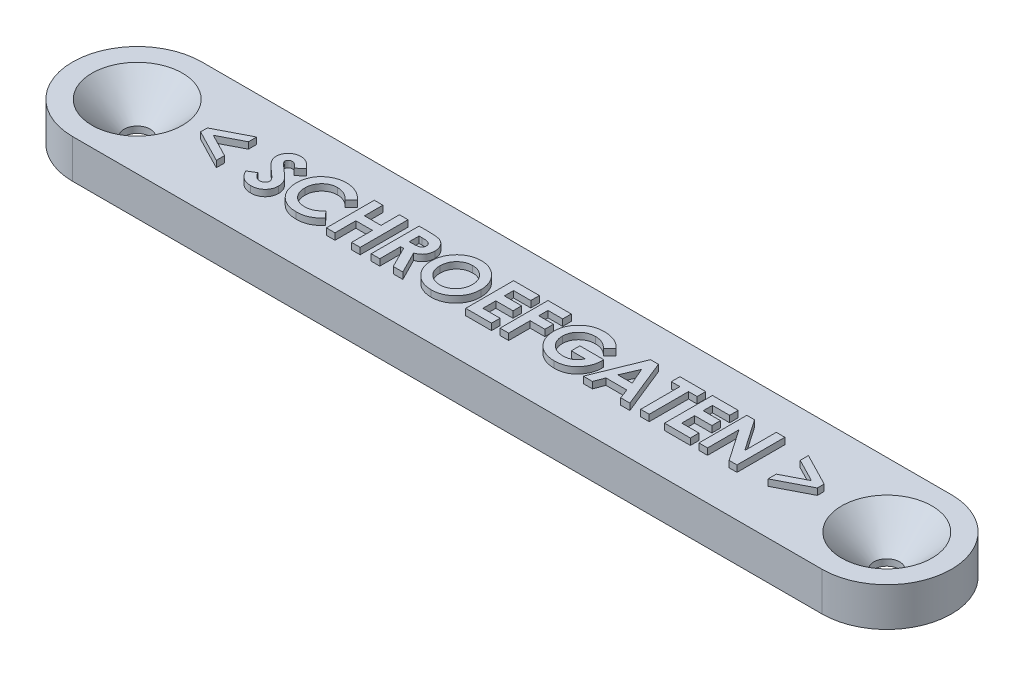
from build123d import *

# Parameters (mm, degrees)
SKETCH1_R           = 1
BOSS_EXTRUDE1_DEPTH = 3
CHAMFER1_SIZE       = 2.5
BOSS_EXTRUDE2_DEPTH = 0.5


with BuildPart() as part:
    # Sketch1 → Boss-Extrude1 (new body)
    with BuildSketch(Plane(origin=(0, 0, 0), x_dir=(1, 0, 0), z_dir=(0, 1, 0))):
        with BuildLine():
            Line((0, 5), (58, 5))
            ThreePointArc((58, 5), (63, 0), (58, -5))
            Line((58, -5), (0, -5))
            ThreePointArc((0, -5), (-5, 0), (0, 5))
        make_face()
        Circle(SKETCH1_R, mode=Mode.SUBTRACT)
        with Locations((58, 0)):
            Circle(SKETCH1_R, mode=Mode.SUBTRACT)
    extrude(amount=BOSS_EXTRUDE1_DEPTH)

    # Chamfer1
    chamfer1_edges = [part.edges().sort_by_distance(p)[0] for p in [
        (-1, 3, 0),
        (57, 3, 0),
    ]]
    chamfer(chamfer1_edges, length=CHAMFER1_SIZE)

    # Sketch2 → Boss-Extrude2 (add)
    with BuildSketch(Plane(origin=(0, 3, 0), x_dir=(1, 0, 0), z_dir=(0, 1, 0))):
        Polygon((7.65355235, -0.897702991), (7.65355235, -1.532130576), (5.13661859, -0.232852564), (5.13661859, 0.290271935), (7.65355235, 1.589549947), (7.65355235, 0.954380342), (5.859346621, 0.028338675), align=None)
        with BuildLine():
            Line((11.690144231, 1.409238949), (11.192990451, 0.954380342))
            add(Edge.make_bspline(
                [(11.192990451, 0.954380342), (11.171694515, 0.984420474), (11.130809288, 1.042093338), (11.064538598, 1.119318662), (10.998567155, 1.185197611), (10.932283772, 1.239454972), (10.86510094, 1.281761092), (10.797135277, 1.311714292), (10.728772101, 1.330755826), (10.682842599, 1.333126955), (10.660219685, 1.334294872)],
                knots=[0, 0, 0, 0, 0.000110419, 0.000211989, 0.00030486, 0.000389805, 0.000468459, 0.000542218, 0.000612051, 0.000679835, 0.000679835, 0.000679835, 0.000679835], degree=3))
            add(Edge.make_bspline(
                [(10.660219685, 1.334294872), (10.63911768, 1.333554826), (10.598375252, 1.332125992), (10.540293898, 1.317923488), (10.488728445, 1.293412051), (10.443729218, 1.261361286), (10.408083192, 1.222747545), (10.379622604, 1.182251658), (10.363596901, 1.137553358), (10.361487604, 1.106852763), (10.360443376, 1.091654147)],
                knots=[0, 0, 0, 0, 6.3229e-05, 0.000122078, 0.000177843, 0.000233653, 0.00028667, 0.000334827, 0.000381296, 0.000426857, 0.000426857, 0.000426857, 0.000426857], degree=3))
            add(Edge.make_bspline(
                [(10.360443376, 1.091654147), (10.361097741, 1.07623636), (10.36241554, 1.04518708), (10.375143685, 0.999680493), (10.394328634, 0.95521526), (10.412660636, 0.928147157), (10.422031083, 0.914311231)],
                knots=[0, 0, 0, 0, 4.6155e-05, 9.2949e-05, 0.000140791, 0.000190815, 0.000190815, 0.000190815, 0.000190815], degree=3))
            add(Edge.make_bspline(
                [(10.422031083, 0.914311231), (10.430549833, 0.903556711), (10.450158871, 0.878801225), (10.487549289, 0.839592394), (10.534503802, 0.791558144), (10.592829317, 0.736350233), (10.660104584, 0.671983167), (10.739447896, 0.600987241), (10.828575407, 0.521163793), (10.891925177, 0.465577634), (10.925121027, 0.436449987)],
                knots=[0, 0, 0, 0, 4.114e-05, 9.47e-05, 0.000162386, 0.000242679, 0.000335586, 0.000441703, 0.00056205, 0.000694537, 0.000694537, 0.000694537, 0.000694537], degree=3))
            add(Edge.make_bspline(
                [(10.925121027, 0.436449987), (10.956280107, 0.409483375), (11.015413568, 0.358306347), (11.099548739, 0.285668774), (11.173489542, 0.22031852), (11.238313126, 0.163236354), (11.293036827, 0.113823352), (11.337890706, 0.071843321), (11.373422575, 0.038113536), (11.393620362, 0.017740725), (11.402240251, 0.00904614)],
                knots=[0, 0, 0, 0, 0.000123624, 0.000234612, 0.000333454, 0.000419663, 0.000493735, 0.000554635, 0.000603967, 0.000640695, 0.000640695, 0.000640695, 0.000640695], degree=3))
            add(Edge.make_bspline(
                [(11.402240251, 0.00904614), (11.434942311, -0.026344492), (11.497807156, -0.094377718), (11.579509292, -0.199807821), (11.646752793, -0.302729099), (11.69877364, -0.405078183), (11.738061876, -0.508331766), (11.765760603, -0.615022138), (11.782349555, -0.726264145), (11.784191316, -0.802173235), (11.785122863, -0.840567408)],
                knots=[0, 0, 0, 0, 0.000144504, 0.000277787, 0.000399634, 0.000512794, 0.000621527, 0.000730412, 0.000842906, 0.000958037, 0.000958037, 0.000958037, 0.000958037], degree=3))
            add(Edge.make_bspline(
                [(11.785122863, -0.840567408), (11.784459812, -0.877977821), (11.783158881, -0.951378443), (11.767224966, -1.058789319), (11.744504138, -1.16158619), (11.709373753, -1.25865048), (11.666557047, -1.351575469), (11.612880123, -1.438913682), (11.549843936, -1.521549016), (11.477594786, -1.598004265), (11.397678648, -1.667382104), (11.311960994, -1.729143895), (11.219603635, -1.780136121), (11.121395657, -1.822124581), (11.017389629, -1.854464655), (10.907709453, -1.878366983), (10.792187366, -1.892712784), (10.713191699, -1.894212468), (10.672834034, -1.894978632)],
                knots=[0, 0, 0, 0, 0.000112134, 0.00022001, 0.000325126, 0.000427449, 0.000529028, 0.000631598, 0.000734298, 0.000840332, 0.000946573, 0.001051377, 0.001156673, 0.001262387, 0.001371279, 0.001482911, 0.001598785, 0.001719816, 0.001719816, 0.001719816, 0.001719816], degree=3))
            add(Edge.make_bspline(
                [(10.672834034, -1.894978632), (10.641153612, -1.894416601), (10.578408206, -1.893303455), (10.485930963, -1.884215551), (10.396633732, -1.869548639), (10.310617097, -1.848526573), (10.227493538, -1.821888765), (10.147259641, -1.789351703), (10.070469288, -1.750411074), (9.996541446, -1.705867653), (9.925835496, -1.654146874), (9.857457389, -1.596306151), (9.792086321, -1.531455868), (9.729408329, -1.459749394), (9.669824443, -1.380983672), (9.611384269, -1.296255662), (9.556685065, -1.203992926), (9.522894933, -1.139269871), (9.505635684, -1.106210771)],
                knots=[0, 0, 0, 0, 9.5025e-05, 0.000188204, 0.000278475, 0.0003663, 0.000453594, 0.000540128, 0.000625743, 0.000711642, 0.000798765, 0.000888264, 0.000980086, 0.001074739, 0.001173729, 0.001276224, 0.001383374, 0.001495244, 0.001495244, 0.001495244, 0.001495244], degree=3))
            Line((9.505635684, -1.106210771), (10.09034789, -0.755235043))
            add(Edge.make_bspline(
                [(10.09034789, -0.755235043), (10.111936631, -0.792761441), (10.153324093, -0.864702753), (10.223459017, -0.961365023), (10.295308666, -1.044140258), (10.370534139, -1.111565398), (10.448220724, -1.164542005), (10.528743664, -1.202402764), (10.612159533, -1.225838531), (10.668978633, -1.228700579), (10.697320713, -1.230128205)],
                knots=[0, 0, 0, 0, 0.000129801, 0.000248839, 0.000357663, 0.000458045, 0.000551067, 0.000638704, 0.000724023, 0.000808938, 0.000808938, 0.000808938, 0.000808938], degree=3))
            add(Edge.make_bspline(
                [(10.697320713, -1.230128205), (10.726148666, -1.228962329), (10.782079094, -1.226700358), (10.861912623, -1.205807221), (10.935107025, -1.173003463), (10.998375725, -1.126197023), (11.051947672, -1.072175277), (11.091486843, -1.012073615), (11.116325617, -0.947045068), (11.118951678, -0.901871961), (11.120272436, -0.879152477)],
                knots=[0, 0, 0, 0, 8.6333e-05, 0.000167499, 0.000245858, 0.000325563, 0.000402174, 0.000472974, 0.000540109, 0.00060804, 0.00060804, 0.00060804, 0.00060804], degree=3))
            add(Edge.make_bspline(
                [(11.120272436, -0.879152477), (11.11905277, -0.858015694), (11.116575135, -0.815078344), (11.098325642, -0.751237407), (11.069796117, -0.687425505), (11.036043678, -0.635085256), (11.001696344, -0.591262184), (10.968852546, -0.553291475), (10.928857489, -0.511340489), (10.881812581, -0.465356454), (10.82833941, -0.414934562), (10.768392931, -0.360079751), (10.701286693, -0.301275225), (10.653855871, -0.261218163), (10.629054821, -0.24027277)],
                knots=[0, 0, 0, 0, 6.335e-05, 0.00012869, 0.000197778, 0.000272501, 0.000314803, 0.000364784, 0.000423045, 0.000488633, 0.00056212, 0.000643529, 0.000732389, 0.000829775, 0.000829775, 0.000829775, 0.000829775], degree=3))
            add(Edge.make_bspline(
                [(10.629054821, -0.24027277), (10.581907038, -0.200381224), (10.491416172, -0.123817274), (10.363541097, -0.01073473), (10.248314204, 0.09495127), (10.146730718, 0.194547234), (10.057496307, 0.286213857), (9.981215304, 0.370695689), (9.918725693, 0.448644393), (9.852968852, 0.540969417), (9.790486705, 0.653473802), (9.736484399, 0.788829619), (9.701449983, 0.924168261), (9.697524864, 1.015027172), (9.695592949, 1.059747262)],
                knots=[0, 0, 0, 0, 0.000185273, 0.000355596, 0.00051208, 0.000654279, 0.00078232, 0.000895827, 0.000995603, 0.001081863, 0.001235664, 0.001380205, 0.001518422, 0.00165239, 0.00165239, 0.00165239, 0.00165239], degree=3))
            add(Edge.make_bspline(
                [(9.695592949, 1.059747262), (9.69639643, 1.09146035), (9.697979373, 1.15393854), (9.712099474, 1.245803614), (9.733202502, 1.334445692), (9.763850158, 1.419541367), (9.803627114, 1.500984054), (9.851934682, 1.579172447), (9.909522988, 1.65338692), (9.97442112, 1.723578272), (10.045922247, 1.787725181), (10.122330286, 1.844341255), (10.203212764, 1.892160015), (10.28807488, 1.931829148), (10.377442492, 1.96219335), (10.47065723, 1.98371701), (10.567852796, 1.996518596), (10.633963122, 1.998258823), (10.66763989, 1.999145299)],
                knots=[0, 0, 0, 0, 9.5083e-05, 0.000187324, 0.000278208, 0.000368103, 0.000458038, 0.00054967, 0.000643321, 0.000739409, 0.000836094, 0.000931076, 0.001024228, 0.001117513, 0.00121161, 0.001306826, 0.00140411, 0.001505122, 0.001505122, 0.001505122, 0.001505122], degree=3))
            add(Edge.make_bspline(
                [(10.66763989, 1.999145299), (10.711283316, 1.99754873), (10.798225662, 1.994368193), (10.926772427, 1.969497439), (11.052331534, 1.930385559), (11.153509414, 1.883201378), (11.234014766, 1.83749404), (11.295714597, 1.79541248), (11.358497497, 1.747205792), (11.422869769, 1.692722064), (11.487635279, 1.630934749), (11.554635619, 1.563314745), (11.622957826, 1.489277656), (11.667356429, 1.436385902), (11.690144231, 1.409238949)],
                knots=[0, 0, 0, 0, 0.00013085, 0.000260668, 0.000391384, 0.000524522, 0.000594654, 0.000668949, 0.000748348, 0.000832052, 0.000921812, 0.001016782, 0.001117609, 0.001223928, 0.001223928, 0.001223928, 0.001223928], degree=3))
        make_face()
        with BuildLine():
            Line((15.774225427, 1.261576856), (15.286717915, 0.795587941))
            add(Edge.make_bspline(
                [(15.286717915, 0.795587941), (15.245363557, 0.838348417), (15.164585538, 0.921873024), (15.034421751, 1.032452242), (14.899056152, 1.124605059), (14.761122008, 1.202215574), (14.618138284, 1.26093346), (14.471758262, 1.303722173), (14.321047261, 1.329808834), (14.219051853, 1.33279361), (14.167750901, 1.334294872)],
                knots=[0, 0, 0, 0, 0.000178394, 0.000348459, 0.000511259, 0.000669024, 0.000822394, 0.000973856, 0.001125852, 0.001279667, 0.001279667, 0.001279667, 0.001279667], degree=3))
            add(Edge.make_bspline(
                [(14.167750901, 1.334294872), (14.124908373, 1.333108822), (14.040363363, 1.330768284), (13.916229134, 1.313609833), (13.797488329, 1.284431139), (13.683734478, 1.244217494), (13.575302308, 1.192183172), (13.471964478, 1.128368446), (13.373975761, 1.053349654), (13.282630533, 0.967514946), (13.199071128, 0.873734077), (13.125241073, 0.773670114), (13.06339656, 0.667552297), (13.012641773, 0.55645531), (12.973105757, 0.439864941), (12.944872073, 0.317859683), (12.928542466, 0.190294237), (12.926105162, 0.103576198), (12.924866453, 0.059503539)],
                knots=[0, 0, 0, 0, 0.000128507, 0.000253594, 0.000375072, 0.000494766, 0.000614909, 0.000735173, 0.000858503, 0.000984498, 0.001110637, 0.001234859, 0.001356905, 0.001478435, 0.001600689, 0.001725604, 0.001853535, 0.001985748, 0.001985748, 0.001985748, 0.001985748], degree=3))
            add(Edge.make_bspline(
                [(12.924866453, 0.059503539), (12.925223435, 0.028570263), (12.925927054, -0.032399858), (12.933629404, -0.12259159), (12.946032004, -0.210098892), (12.963981639, -0.294789214), (12.986427835, -0.37673595), (13.012762333, -0.456646049), (13.045798574, -0.533415335), (13.082469299, -0.607935432), (13.12511693, -0.678172967), (13.171098944, -0.745150286), (13.220958931, -0.808539072), (13.275019837, -0.868080191), (13.334042501, -0.922843148), (13.396501407, -0.97447473), (13.46345015, -1.021682424), (13.533498034, -1.065650959), (13.607250185, -1.103846799), (13.682705536, -1.138444852), (13.761008143, -1.166543614), (13.841204623, -1.18919378), (13.923008383, -1.208454364), (14.007219541, -1.220313697), (14.093108089, -1.229294631), (14.151154332, -1.229849151), (14.180365251, -1.230128205)],
                knots=[0, 0, 0, 0, 9.2779e-05, 0.00018287, 0.000271332, 0.000357777, 0.00044238, 0.00052615, 0.000609942, 0.000692903, 0.00077511, 0.000856204, 0.000936514, 0.001016875, 0.001097195, 0.001177857, 0.001259803, 0.001342783, 0.00142576, 0.001508787, 0.001591644, 0.001675018, 0.001758722, 0.001843514, 0.001929975, 0.002017561, 0.002017561, 0.002017561, 0.002017561], degree=3))
            add(Edge.make_bspline(
                [(14.180365251, -1.230128205), (14.229911991, -1.22869505), (14.32725845, -1.225879274), (14.470128376, -1.203860303), (14.606269182, -1.167640342), (14.715045035, -1.124866672), (14.800268042, -1.082627118), (14.865147058, -1.04355761), (14.932237017, -0.999854076), (15.000423612, -0.949867097), (15.070473807, -0.894196538), (15.141151056, -0.831623107), (15.214264707, -0.76420726), (15.262160735, -0.716091246), (15.286717915, -0.691421274)],
                knots=[0, 0, 0, 0, 0.00014859, 0.00029194, 0.000432513, 0.000570443, 0.000641789, 0.000717635, 0.000797488, 0.000881938, 0.000971169, 0.001065822, 0.001165056, 0.00126947, 0.00126947, 0.00126947, 0.00126947], degree=3))
            Line((15.286717915, -0.691421274), (15.759385016, -1.187833033))
            add(Edge.make_bspline(
                [(15.759385016, -1.187833033), (15.726159063, -1.219911647), (15.661309108, -1.282522243), (15.563484752, -1.371423446), (15.465783511, -1.451311059), (15.370565645, -1.525084654), (15.276271385, -1.590595025), (15.182910731, -1.647907599), (15.091540567, -1.698471894), (15.000263561, -1.741435168), (14.908511742, -1.77791545), (14.814109901, -1.809322578), (14.716769446, -1.835891879), (14.615895863, -1.857329815), (14.512430041, -1.874520145), (14.405403676, -1.886123519), (14.295495369, -1.893924081), (14.220942862, -1.894625026), (14.183333333, -1.894978632)],
                knots=[0, 0, 0, 0, 0.000138553, 0.000270426, 0.000396406, 0.000517066, 0.000631715, 0.000740653, 0.000845591, 0.000944838, 0.001043083, 0.001141635, 0.001243159, 0.001345617, 0.001450892, 0.001557663, 0.001668473, 0.001781282, 0.001781282, 0.001781282, 0.001781282], degree=3))
            add(Edge.make_bspline(
                [(14.183333333, -1.894978632), (14.114249287, -1.893217542), (13.979071012, -1.889771579), (13.780970775, -1.86423932), (13.592780867, -1.821434938), (13.414043458, -1.760897735), (13.244815382, -1.683564296), (13.085139933, -1.588757131), (12.935274472, -1.476728128), (12.796429617, -1.348790375), (12.670837837, -1.207493868), (12.559829248, -1.055780182), (12.46800294, -0.8929037), (12.391757577, -0.721270629), (12.332134706, -0.540097741), (12.290170313, -0.34918906), (12.264291177, -0.148728922), (12.261459963, -0.011810027), (12.260016026, 0.058019498)],
                knots=[0, 0, 0, 0, 0.000207215, 0.000405462, 0.000598064, 0.000785315, 0.00097059, 0.001155239, 0.001341339, 0.001530914, 0.001720647, 0.00190766, 0.002093758, 0.002280452, 0.002470283, 0.002664892, 0.002866084, 0.003075493, 0.003075493, 0.003075493, 0.003075493], degree=3))
            add(Edge.make_bspline(
                [(12.260016026, 0.058019498), (12.260626164, 0.103561718), (12.261835308, 0.193815268), (12.274543529, 0.326766059), (12.292259527, 0.456369299), (12.320364347, 0.581279276), (12.354241936, 0.70317876), (12.396373169, 0.820742844), (12.446690757, 0.934309419), (12.503572844, 1.044068604), (12.567922981, 1.149301357), (12.639809148, 1.249103564), (12.717380715, 1.344245679), (12.8025016, 1.433465465), (12.893934886, 1.517546289), (12.992093383, 1.596032502), (13.096386717, 1.670049684), (13.207097172, 1.737689112), (13.322073937, 1.798872569), (13.439866854, 1.852838992), (13.560186518, 1.897942493), (13.682524209, 1.935354184), (13.8073968, 1.963279366), (13.933912983, 1.984417828), (14.063149258, 1.996234363), (14.149920221, 1.998168806), (14.193721621, 1.999145299)],
                knots=[0, 0, 0, 0, 0.000136582, 0.000270673, 0.000400375, 0.000528747, 0.000654421, 0.000779754, 0.000903012, 0.001026805, 0.001150375, 0.00127269, 0.001395536, 0.001518353, 0.001642291, 0.001767909, 0.001895142, 0.002025712, 0.002156831, 0.00228567, 0.002414116, 0.002542048, 0.002669133, 0.002797708, 0.002926625, 0.003058038, 0.003058038, 0.003058038, 0.003058038], degree=3))
            add(Edge.make_bspline(
                [(14.193721621, 1.999145299), (14.231088707, 1.998585549), (14.305434364, 1.997471868), (14.416147523, 1.988188125), (14.52597525, 1.973608101), (14.634524328, 1.951609949), (14.742571211, 1.925495363), (14.848696042, 1.891301915), (14.954572997, 1.853186874), (15.058541555, 1.807628124), (15.160746838, 1.757896634), (15.258794529, 1.701474452), (15.354330837, 1.641833736), (15.445238737, 1.575444689), (15.533221129, 1.504715363), (15.617817946, 1.429315767), (15.6982868, 1.347988768), (15.748784584, 1.290526443), (15.774225427, 1.261576856)],
                knots=[0, 0, 0, 0, 0.000112084, 0.000223003, 0.000333085, 0.000444265, 0.000555124, 0.000666363, 0.000778573, 0.000892569, 0.001006724, 0.001119377, 0.001231775, 0.001344431, 0.001456839, 0.001570346, 0.001684205, 0.001799807, 0.001799807, 0.001799807, 0.001799807], degree=3))
        make_face()
        Polygon((16.439075855, 1.904166667), (17.103926282, 1.904166667), (17.103926282, 0.479487179), (18.386137821, 0.479487179), (18.386137821, 1.904166667), (19.050988248, 1.904166667), (19.050988248, -1.8), (18.386137821, -1.8), (18.386137821, -0.185363248), (17.103926282, -0.185363248), (17.103926282, -1.8), (16.439075855, -1.8), align=None)
        with BuildLine():
            Line((19.90579594, 1.904166667), (20.680465411, 1.904166667))
            add(Edge.make_bspline(
                [(20.680465411, 1.904166667), (20.731670828, 1.903984917), (20.830153267, 1.903635361), (20.972159565, 1.898120291), (21.102611879, 1.890445618), (21.221703355, 1.878733864), (21.329383045, 1.863205494), (21.425758867, 1.844900116), (21.510828005, 1.824037212), (21.585307901, 1.798040388), (21.652522323, 1.768716365), (21.715175509, 1.735022525), (21.774649682, 1.697334059), (21.830547321, 1.654659282), (21.883354188, 1.607765903), (21.933169909, 1.556606718), (21.979290539, 1.50074792), (22.0214305, 1.440542464), (22.059837681, 1.377207705), (22.093781575, 1.310656684), (22.121384805, 1.240843118), (22.145775218, 1.168775966), (22.163342843, 1.093425013), (22.175560868, 1.015523813), (22.184506429, 0.934798146), (22.185020756, 0.879956711), (22.18528312, 0.851981504)],
                knots=[0, 0, 0, 0, 0.000153605, 0.000295427, 0.000426277, 0.000545592, 0.000654308, 0.000752538, 0.000839823, 0.000916793, 0.000988895, 0.001059605, 0.001130003, 0.001199903, 0.001270336, 0.001341702, 0.001413907, 0.0014874, 0.001561973, 0.001635974, 0.001711208, 0.001786999, 0.00186403, 0.001942957, 0.00202351, 0.002107388, 0.002107388, 0.002107388, 0.002107388], degree=3))
            add(Edge.make_bspline(
                [(22.18528312, 0.851981504), (22.184601593, 0.822781813), (22.183265243, 0.765526543), (22.176066938, 0.681423219), (22.162910697, 0.600959043), (22.142983655, 0.524369601), (22.120080109, 0.450701651), (22.089624269, 0.38131441), (22.055251842, 0.315198744), (22.014428715, 0.253289882), (21.969627328, 0.194212705), (21.917524257, 0.140230679), (21.861494981, 0.088442475), (21.79838989, 0.042091929), (21.730990716, -0.001955014), (21.657958307, -0.041873274), (21.579769298, -0.078666305), (21.524798553, -0.099184641), (21.496688034, -0.10967715)],
                knots=[0, 0, 0, 0, 8.7609e-05, 0.000171785, 0.000253028, 0.000331854, 0.000409056, 0.000484176, 0.000558859, 0.000632334, 0.000706395, 0.00078093, 0.000857099, 0.000935011, 0.001015485, 0.001098512, 0.00118449, 0.001274471, 0.001274471, 0.001274471, 0.001274471], degree=3))
            Line((21.496688034, -0.10967715), (22.351495726, -1.8))
            Line((22.351495726, -1.8), (21.612443243, -1.8))
            Line((21.612443243, -1.8), (20.79622062, -0.185363248))
            Line((20.79622062, -0.185363248), (20.570646368, -0.185363248))
            Line((20.570646368, -0.185363248), (20.570646368, -1.8))
            Line((20.570646368, -1.8), (19.90579594, -1.8))
            Line((19.90579594, -1.8), (19.90579594, 1.904166667))
        make_face()
        with BuildLine():
            Line((20.570646368, 0.479487179), (20.829611545, 0.479487179))
            add(Edge.make_bspline(
                [(20.829611545, 0.479487179), (20.861272191, 0.479843763), (20.921895524, 0.480526544), (21.00907984, 0.483693564), (21.088263991, 0.491324517), (21.15978802, 0.500965941), (21.224011831, 0.512098358), (21.28036257, 0.528051787), (21.329708515, 0.54514629), (21.371464914, 0.566390323), (21.407140623, 0.590549396), (21.437944314, 0.617994704), (21.463423383, 0.649759153), (21.484393956, 0.684979522), (21.500706783, 0.723967328), (21.512613896, 0.766294572), (21.519268212, 0.812443416), (21.520033813, 0.844292402), (21.520432692, 0.860885751)],
                knots=[0, 0, 0, 0, 9.499e-05, 0.000181886, 0.000261628, 0.000333512, 0.000398421, 0.000456928, 0.000509039, 0.000554834, 0.000597025, 0.000638004, 0.000678101, 0.000718696, 0.000760592, 0.000804522, 0.000850275, 0.00090004, 0.00090004, 0.00090004, 0.00090004], degree=3))
            add(Edge.make_bspline(
                [(21.520432692, 0.860885751), (21.519678575, 0.880516893), (21.518197251, 0.919078635), (21.503497914, 0.974594022), (21.480099744, 1.025977311), (21.448027262, 1.072996339), (21.407636141, 1.114216465), (21.361284143, 1.150552334), (21.307970879, 1.179284021), (21.258606809, 1.198235136), (21.213697044, 1.209573783), (21.173167397, 1.218023243), (21.126233823, 1.224011617), (21.072860888, 1.230363355), (21.013184642, 1.234482135), (20.946879814, 1.237488023), (20.87413683, 1.23871788), (20.823428062, 1.239111043), (20.79696264, 1.239316239)],
                knots=[0, 0, 0, 0, 5.8788e-05, 0.000115479, 0.000170932, 0.000227531, 0.000285256, 0.000343437, 0.000403545, 0.000466249, 0.000501525, 0.000542417, 0.000590373, 0.00064339, 0.000703658, 0.000769765, 0.000842498, 0.000921898, 0.000921898, 0.000921898, 0.000921898], degree=3))
            Line((20.79696264, 1.239316239), (20.570646368, 1.239316239))
            Line((20.570646368, 1.239316239), (20.570646368, 0.479487179))
        make_face(mode=Mode.SUBTRACT)
        with BuildLine():
            add(Edge.make_bspline(
                [(24.638403112, 1.999145299), (24.702804589, 1.99747783), (24.829947691, 1.994185867), (25.016929314, 1.966744789), (25.197120681, 1.922033487), (25.370440308, 1.859881544), (25.536454225, 1.778605568), (25.695748018, 1.680509787), (25.847751104, 1.563742702), (25.990905877, 1.431028297), (26.123206705, 1.286707176), (26.237845451, 1.131319831), (26.335605167, 0.968892504), (26.416628681, 0.798989967), (26.478343169, 0.620435563), (26.521650777, 0.434139684), (26.54947377, 0.240155329), (26.552673842, 0.108078423), (26.554300214, 0.040953025)],
                knots=[0, 0, 0, 0, 0.000193131, 0.000381284, 0.000565569, 0.000749353, 0.00093254, 0.001119111, 0.00130967, 0.001506585, 0.001704094, 0.001896132, 0.002084852, 0.002272053, 0.002459786, 0.002650387, 0.002845153, 0.003046437, 0.003046437, 0.003046437, 0.003046437], degree=3))
            add(Edge.make_bspline(
                [(26.554300214, 0.040953025), (26.552568198, -0.025416025), (26.549155206, -0.156198368), (26.522786633, -0.348395081), (26.47874972, -0.532695343), (26.418081958, -0.709516322), (26.338527904, -0.878001559), (26.242674609, -1.039226808), (26.127992686, -1.191695859), (25.998665036, -1.335326893), (25.856286516, -1.465702876), (25.705485062, -1.580596486), (25.546956981, -1.677952995), (25.380934307, -1.75772781), (25.207061013, -1.819638106), (25.025766587, -1.863320318), (24.837062248, -1.88986688), (24.708734146, -1.893257579), (24.643597256, -1.894978632)],
                knots=[0, 0, 0, 0, 0.000199061, 0.000392256, 0.000580691, 0.000766778, 0.000952004, 0.001138688, 0.001328498, 0.001523412, 0.001717728, 0.001906798, 0.002091327, 0.002274859, 0.002458392, 0.002643942, 0.002833461, 0.003028815, 0.003028815, 0.003028815, 0.003028815], degree=3))
            add(Edge.make_bspline(
                [(24.643597256, -1.894978632), (24.575471878, -1.893434762), (24.441614824, -1.890401269), (24.245714425, -1.86155413), (24.058024916, -1.818100261), (23.880122997, -1.753247693), (23.710196888, -1.672176531), (23.549495086, -1.572332533), (23.398071598, -1.453880701), (23.256795014, -1.319854629), (23.128798087, -1.17320071), (23.015815692, -1.018273849), (22.920512536, -0.856257553), (22.842885131, -0.687075993), (22.781686803, -0.511780592), (22.738518336, -0.32930375), (22.713017693, -0.140083113), (22.709465601, -0.011560674), (22.707665598, 0.053567374)],
                knots=[0, 0, 0, 0, 0.00020425, 0.000401323, 0.000592818, 0.000781292, 0.000968143, 0.001156756, 0.001347635, 0.001543938, 0.001740086, 0.001930808, 0.002118391, 0.002302992, 0.002488378, 0.002674476, 0.00286463, 0.003059984, 0.003059984, 0.003059984, 0.003059984], degree=3))
            add(Edge.make_bspline(
                [(22.707665598, 0.053567374), (22.708230543, 0.097382116), (22.709353279, 0.184456803), (22.722877815, 0.313497045), (22.742349258, 0.440018595), (22.771146599, 0.563517009), (22.806128008, 0.684863511), (22.851451364, 0.802928579), (22.903041609, 0.918973471), (22.963319954, 1.031627552), (23.030343644, 1.139854311), (23.103472457, 1.243143223), (23.182890275, 1.340245374), (23.268341267, 1.431798879), (23.360119907, 1.517201951), (23.457018944, 1.597663589), (23.560917653, 1.671046445), (23.669542019, 1.739142676), (23.782279642, 1.800720917), (23.898671577, 1.853134474), (24.016319922, 1.89890634), (24.136796298, 1.935031521), (24.258809588, 1.964455103), (24.383663256, 1.983913423), (24.51022932, 1.997437584), (24.59557712, 1.99857471), (24.638403112, 1.999145299)],
                knots=[0, 0, 0, 0, 0.00013139, 0.000261116, 0.000388841, 0.000515202, 0.000641287, 0.000767389, 0.000894264, 0.001022066, 0.001150352, 0.001275944, 0.001401453, 0.001526399, 0.001651346, 0.001777325, 0.001903952, 0.00203263, 0.002161789, 0.002288969, 0.002415335, 0.002540211, 0.002666018, 0.002791544, 0.002919055, 0.003047478, 0.003047478, 0.003047478, 0.003047478], degree=3))
        make_face()
        with BuildLine():
            add(Edge.make_bspline(
                [(24.628014824, 1.334294872), (24.584672638, 1.333131904), (24.499132508, 1.33083667), (24.373660715, 1.313350093), (24.253203362, 1.285422042), (24.138428193, 1.244968602), (24.028837762, 1.193481639), (23.924237798, 1.131141056), (23.826076796, 1.055803965), (23.733045874, 0.971514878), (23.649007743, 0.877597464), (23.574757404, 0.776948983), (23.512621829, 0.669737516), (23.460582896, 0.556959032), (23.421409113, 0.437345367), (23.393506802, 0.311833467), (23.375873583, 0.18020707), (23.373650893, 0.090477526), (23.372516026, 0.044663128)],
                knots=[0, 0, 0, 0, 0.000129989, 0.000256547, 0.000379294, 0.000500387, 0.000620883, 0.00074203, 0.00086491, 0.000991491, 0.001118125, 0.001242346, 0.001366048, 0.001489237, 0.001614304, 0.001742837, 0.001874543, 0.002011945, 0.002011945, 0.002011945, 0.002011945], degree=3))
            add(Edge.make_bspline(
                [(23.372516026, 0.044663128), (23.374020687, -0.006109532), (23.376969574, -0.105615532), (23.397718302, -0.250772203), (23.43321731, -0.387858273), (23.484477188, -0.516203273), (23.548052885, -0.637232378), (23.62700381, -0.749462206), (23.720051332, -0.853564735), (23.79173439, -0.914344127), (23.828116653, -0.945192308)],
                knots=[0, 0, 0, 0, 0.000152295, 0.000298473, 0.000438856, 0.000576096, 0.000712192, 0.000848054, 0.000986766, 0.001129728, 0.001129728, 0.001129728, 0.001129728], degree=3))
            add(Edge.make_bspline(
                [(23.828116653, -0.945192308), (23.857920673, -0.967981759), (23.916857223, -1.01304721), (24.010932788, -1.070807831), (24.107812096, -1.120314446), (24.208226222, -1.160315205), (24.311963097, -1.191779129), (24.419008496, -1.213812798), (24.529210744, -1.227640831), (24.603734669, -1.229293543), (24.641371194, -1.230128205)],
                knots=[0, 0, 0, 0, 0.000112494, 0.000222453, 0.000330636, 0.000438525, 0.000546271, 0.000655417, 0.000766045, 0.00087892, 0.00087892, 0.00087892, 0.00087892], degree=3))
            add(Edge.make_bspline(
                [(24.641371194, -1.230128205), (24.68396811, -1.228955376), (24.767778881, -1.226647799), (24.890914949, -1.209376491), (25.008883042, -1.180147203), (25.122415516, -1.140048634), (25.231184994, -1.087915209), (25.33465989, -1.023641016), (25.433021624, -0.948015262), (25.525934027, -0.862619275), (25.610860355, -0.768331891), (25.684955749, -0.667146562), (25.749066925, -0.561292701), (25.800023707, -0.449272109), (25.840745158, -0.332142208), (25.86831165, -0.209384254), (25.88609383, -0.081504302), (25.888317146, 0.005522525), (25.889449786, 0.049857272)],
                knots=[0, 0, 0, 0, 0.000127766, 0.000251383, 0.000372141, 0.000491834, 0.000611977, 0.000733263, 0.000856592, 0.000983675, 0.001111357, 0.001236615, 0.001359417, 0.001481931, 0.001605127, 0.001730765, 0.001858793, 0.001991748, 0.001991748, 0.001991748, 0.001991748], degree=3))
            add(Edge.make_bspline(
                [(25.889449786, 0.049857272), (25.888277956, 0.093937081), (25.885971387, 0.180701464), (25.868669681, 0.308252638), (25.839625757, 0.430468652), (25.799406777, 0.547549097), (25.748049269, 0.659608757), (25.6845405, 0.766253564), (25.609103315, 0.867380417), (25.523473895, 0.962300176), (25.430271535, 1.049525354), (25.330209489, 1.125220953), (25.226087605, 1.190998022), (25.115516819, 1.242525121), (25.000759317, 1.283576652), (24.881114842, 1.313807589), (24.756130234, 1.330713826), (24.671100621, 1.33309055), (24.628014824, 1.334294872)],
                knots=[0, 0, 0, 0, 0.000132213, 0.000260241, 0.000385326, 0.000508522, 0.000631036, 0.000754475, 0.000880174, 0.001008904, 0.001137539, 0.001262498, 0.001384806, 0.001506289, 0.001627629, 0.001750006, 0.001875829, 0.002005077, 0.002005077, 0.002005077, 0.002005077], degree=3))
        make_face(mode=Mode.SUBTRACT)
        Polygon((27.219150641, 1.904166667), (29.213701923, 1.904166667), (29.213701923, 1.239316239), (27.884001068, 1.239316239), (27.884001068, 0.526976496), (29.213701923, 0.526976496), (29.213701923, -0.137873932), (27.884001068, -0.137873932), (27.884001068, -1.135149573), (29.213701923, -1.135149573), (29.213701923, -1.8), (27.219150641, -1.8), align=None)
        Polygon((29.87855235, 1.904166667), (31.683146368, 1.904166667), (31.683146368, 1.239316239), (30.543402778, 1.239316239), (30.543402778, 0.526976496), (31.683146368, 0.526976496), (31.683146368, -0.137873932), (30.543402778, -0.137873932), (30.543402778, -1.8), (29.87855235, -1.8), align=None)
        with BuildLine():
            Line((35.742740885, 1.315002337), (35.239650942, 0.83343099))
            add(Edge.make_bspline(
                [(35.239650942, 0.83343099), (35.199820433, 0.873309222), (35.121666399, 0.951556898), (34.993855253, 1.053401627), (34.861481696, 1.139989779), (34.724110032, 1.211188615), (34.581548903, 1.266416622), (34.434079642, 1.305922983), (34.281462336, 1.329354875), (34.178147232, 1.33263526), (34.125878072, 1.334294872)],
                knots=[0, 0, 0, 0, 0.000168979, 0.000331564, 0.000489215, 0.000642871, 0.000794862, 0.000946954, 0.001100064, 0.001256843, 0.001256843, 0.001256843, 0.001256843], degree=3))
            add(Edge.make_bspline(
                [(34.125878072, 1.334294872), (34.080562307, 1.333131989), (33.991580832, 1.330848567), (33.860831124, 1.313508419), (33.735891769, 1.28454248), (33.616172502, 1.244415008), (33.502404249, 1.192196485), (33.393927818, 1.128692841), (33.291410773, 1.05341827), (33.195660361, 0.967799714), (33.108479303, 0.874321538), (33.032365636, 0.774266835), (32.967533143, 0.669500541), (32.914162779, 0.559486654), (32.873553736, 0.444394025), (32.844564194, 0.324306206), (32.826163043, 0.199572187), (32.823990417, 0.114477347), (32.822889957, 0.071375868)],
                knots=[0, 0, 0, 0, 0.000135919, 0.00026689, 0.000394864, 0.000520167, 0.000645014, 0.000769731, 0.000896625, 0.001025907, 0.001154542, 0.001279502, 0.00140244, 0.001523573, 0.001645613, 0.001767812, 0.001893737, 0.002022985, 0.002022985, 0.002022985, 0.002022985], degree=3))
            add(Edge.make_bspline(
                [(32.822889957, 0.071375868), (32.823916413, 0.026782589), (32.825938671, -0.061072276), (32.845364749, -0.190003066), (32.875293966, -0.314043777), (32.91910236, -0.432274056), (32.973017226, -0.546313492), (33.041390159, -0.653953032), (33.12111984, -0.756836451), (33.212063805, -0.85317249), (33.310987353, -0.941971132), (33.418124773, -1.018571127), (33.53021629, -1.084660388), (33.649071065, -1.137000947), (33.77262613, -1.179024681), (33.90213469, -1.20865502), (34.037305122, -1.22683313), (34.12953069, -1.229018913), (34.17633547, -1.230128205)],
                knots=[0, 0, 0, 0, 0.000133696, 0.000263399, 0.000390275, 0.000515861, 0.000640981, 0.000768008, 0.000897581, 0.001030918, 0.001164945, 0.001295713, 0.001425397, 0.001554607, 0.001684602, 0.001816358, 0.001952575, 0.002092943, 0.002092943, 0.002092943, 0.002092943], degree=3))
            add(Edge.make_bspline(
                [(34.17633547, -1.230128205), (34.206780247, -1.229853507), (34.266550117, -1.229314214), (34.354222331, -1.220559969), (34.438191254, -1.208044757), (34.518782075, -1.191476104), (34.595181042, -1.168028486), (34.668445951, -1.140609384), (34.738147535, -1.108249377), (34.803907879, -1.069831983), (34.866705688, -1.026770781), (34.925953162, -0.977499609), (34.98268957, -0.923129351), (35.036251957, -0.862995796), (35.085733762, -0.79656128), (35.132720257, -0.725046626), (35.176673455, -0.647742094), (35.20264424, -0.593153549), (35.215906283, -0.565277778)],
                knots=[0, 0, 0, 0, 9.1296e-05, 0.000179234, 0.000264026, 0.000345961, 0.000425776, 0.000503504, 0.000580517, 0.000655988, 0.000731732, 0.000808688, 0.000886882, 0.000967298, 0.00104996, 0.001135163, 0.001223886, 0.001316472, 0.001316472, 0.001316472, 0.001316472], degree=3))
            Line((35.215906283, -0.565277778), (34.152590812, -0.565277778))
            Line((34.152590812, -0.565277778), (34.152590812, 0.09957265))
            Line((34.152590812, 0.09957265), (35.999480001, 0.09957265))
            Line((35.999480001, 0.09957265), (36.004674145, -0.058477731))
            add(Edge.make_bspline(
                [(36.004674145, -0.058477731), (36.004006736, -0.099069079), (36.00267311, -0.180179336), (35.990485161, -0.300938691), (35.97029601, -0.420096424), (35.942695507, -0.537532855), (35.908105095, -0.653824053), (35.863991492, -0.767856431), (35.812334733, -0.880403321), (35.754456999, -0.990986485), (35.689419079, -1.097094037), (35.619396207, -1.197563882), (35.54538661, -1.292222128), (35.465780607, -1.379749948), (35.381817795, -1.460882616), (35.293332893, -1.535308003), (35.200012934, -1.603089083), (35.102352271, -1.664798451), (34.999794633, -1.718883072), (34.892903882, -1.765929516), (34.781841407, -1.805885068), (34.666320471, -1.838639929), (34.546568392, -1.86391291), (34.422582602, -1.881242626), (34.294295009, -1.893018363), (34.207280249, -1.89431731), (34.1629791, -1.894978632)],
                knots=[0, 0, 0, 0, 0.000121748, 0.000243279, 0.00036368, 0.000484091, 0.000604986, 0.000727357, 0.000850545, 0.000976341, 0.001101565, 0.001223629, 0.001343573, 0.001461768, 0.001578268, 0.001693606, 0.001808334, 0.001924035, 0.002039878, 0.002155828, 0.002274124, 0.002393681, 0.002515781, 0.002640972, 0.002769084, 0.002901957, 0.002901957, 0.002901957, 0.002901957], degree=3))
            add(Edge.make_bspline(
                [(34.1629791, -1.894978632), (34.115712778, -1.894325564), (34.022016829, -1.893030988), (33.883474812, -1.8809064), (33.748951985, -1.860895549), (33.618414795, -1.833201217), (33.491560161, -1.798733407), (33.368606039, -1.755468153), (33.249803903, -1.704002765), (33.134797996, -1.645700067), (33.02505822, -1.579579728), (32.920830518, -1.506801177), (32.822683786, -1.426896263), (32.729612696, -1.341202611), (32.643791749, -1.247613863), (32.562022733, -1.149163685), (32.488267078, -1.042241316), (32.41935351, -0.930313212), (32.358130145, -0.813426275), (32.304589432, -0.693742391), (32.258929942, -0.571954529), (32.222926331, -0.447495605), (32.193694771, -0.321233449), (32.172779041, -0.192618978), (32.160966951, -0.061668291), (32.159019669, 0.026337354), (32.15803953, 0.070633847)],
                knots=[0, 0, 0, 0, 0.000141774, 0.000281039, 0.000416831, 0.000549555, 0.000681146, 0.000810924, 0.000940216, 0.001069307, 0.001197453, 0.001324258, 0.001450343, 0.001576881, 0.001703418, 0.001831016, 0.001960496, 0.002092719, 0.002225151, 0.002356018, 0.002485854, 0.002614996, 0.002744416, 0.002874456, 0.00300559, 0.003138487, 0.003138487, 0.003138487, 0.003138487], degree=3))
            add(Edge.make_bspline(
                [(32.15803953, 0.070633847), (32.159352145, 0.131063731), (32.161944171, 0.250394834), (32.185950267, 0.426170305), (32.223372194, 0.596215535), (32.277076427, 0.759911231), (32.345991639, 0.917482884), (32.429141585, 1.069300402), (32.528332461, 1.215202416), (32.605113012, 1.305536027), (32.644063001, 1.351361345)],
                knots=[0, 0, 0, 0, 0.000181205, 0.000357826, 0.000531188, 0.000702952, 0.000873754, 0.001046439, 0.001221584, 0.001401912, 0.001401912, 0.001401912, 0.001401912], degree=3))
            add(Edge.make_bspline(
                [(32.644063001, 1.351361345), (32.668246669, 1.37787268), (32.716250885, 1.430497282), (32.792985538, 1.503620237), (32.871666204, 1.57235852), (32.953382621, 1.635254579), (33.037705222, 1.693685239), (33.124876703, 1.74655517), (33.214439781, 1.795547779), (33.307092941, 1.838161318), (33.40235113, 1.87636791), (33.500636232, 1.908696059), (33.601212112, 1.937331115), (33.704969372, 1.959115048), (33.810859816, 1.977255046), (33.919635091, 1.989413422), (34.030998777, 1.998324646), (34.106319573, 1.998869584), (34.144428586, 1.999145299)],
                knots=[0, 0, 0, 0, 0.000107624, 0.000213631, 0.000317779, 0.00042093, 0.000522815, 0.000625385, 0.000726651, 0.000828902, 0.000931142, 0.001034387, 0.001139167, 0.001244683, 0.001352276, 0.001461343, 0.001572945, 0.001687238, 0.001687238, 0.001687238, 0.001687238], degree=3))
            add(Edge.make_bspline(
                [(34.144428586, 1.999145299), (34.184264877, 1.998530955), (34.263524468, 1.997308636), (34.381370355, 1.988850984), (34.497578694, 1.975802822), (34.611659772, 1.956229833), (34.723996446, 1.932092264), (34.834007234, 1.901166064), (34.94240982, 1.866028329), (35.012979494, 1.838013932), (35.048209635, 1.824028446)],
                knots=[0, 0, 0, 0, 0.000119502, 0.000237765, 0.000354289, 0.000470177, 0.000584867, 0.000698822, 0.000812861, 0.000926548, 0.000926548, 0.000926548, 0.000926548], degree=3))
            add(Edge.make_bspline(
                [(35.048209635, 1.824028446), (35.077851442, 1.811103339), (35.138142056, 1.784814029), (35.225857468, 1.736716504), (35.313787194, 1.683394878), (35.400982426, 1.622899587), (35.487310303, 1.555343787), (35.57367218, 1.481794509), (35.659186444, 1.401394127), (35.714528709, 1.344172545), (35.742740885, 1.315002337)],
                knots=[0, 0, 0, 0, 9.6967e-05, 0.000197227, 0.000299798, 0.000405389, 0.000515374, 0.000628534, 0.000745597, 0.000867329, 0.000867329, 0.000867329, 0.000867329], degree=3))
        make_face()
        Polygon((37.810010183, 1.904166667), (38.426629274, 1.904166667), (39.922542735, -1.8), (39.212429053, -1.8), (38.924525073, -1.04017094), (37.310630342, -1.04017094), (37.022726362, -1.8), (36.313354701, -1.8), align=None)
        Polygon((38.117948718, 0.910601128), (37.562917334, -0.375320513), (38.672980101, -0.375320513), align=None, mode=Mode.SUBTRACT)
        Polygon((40.088755342, 1.904166667), (42.083306624, 1.904166667), (42.083306624, 1.239316239), (41.418456197, 1.239316239), (41.418456197, -1.8), (40.753605769, -1.8), (40.753605769, 1.239316239), (40.088755342, 1.239316239), align=None)
        Polygon((42.605689103, 1.904166667), (44.600240385, 1.904166667), (44.600240385, 1.239316239), (43.27053953, 1.239316239), (43.27053953, 0.526976496), (44.600240385, 0.526976496), (44.600240385, -0.137873932), (43.27053953, -0.137873932), (43.27053953, -1.135149573), (44.600240385, -1.135149573), (44.600240385, -1.8), (42.605689103, -1.8), align=None)
        Polygon((45.265090812, 1.904166667), (45.863901409, 1.904166667), (47.544577991, -0.533370893), (47.544577991, 1.904166667), (48.209428419, 1.904166667), (48.209428419, -1.8), (47.606165698, -1.8), (45.929941239, 0.630117354), (45.929941239, -1.8), (45.265090812, -1.8), align=None)
        Polygon((50.34644765, 0.954380342), (50.34644765, 1.589549947), (52.86338141, 0.291755976), (52.86338141, -0.235078626), (50.34644765, -1.532130576), (50.34644765, -0.897702991), (52.14287944, 0.028338675), align=None)
    extrude(amount=BOSS_EXTRUDE2_DEPTH)


solid = part.part
